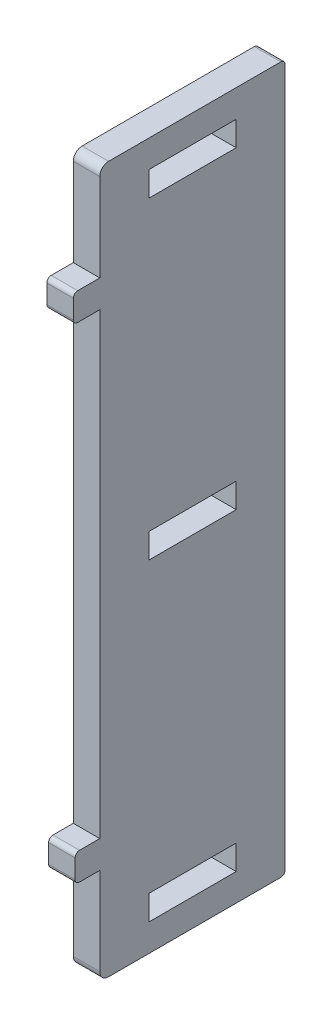
from build123d import *

# Parameters (mm, degrees)
SKETCH_1_W      = 9.9
SKETCH_1_H      = 2.8
SKETCH_1_W_2    = 3
SKETCH_1_H_2    = 3.12
EXTRUDE_1_DEPTH = 3
FILLET_1_R      = 1
FILLET_2_R      = 0.5


with BuildPart() as part:
    # Эскиз1 → Бобышка-Вытянуть1 (new body)
    with BuildSketch(Plane(origin=(0, 0, 0), x_dir=(0, 0, -1), z_dir=(1, 0, 0))):
        Polygon((-13.3, -25.94), (-13.3, -29.06), (-10.5, -29.06), (-10.5, -40), (10.5, -40), (10.5, 40), (-10.5, 40), (-10.5, -25.94), align=None)
        with Locations((0, 35.5)):
            Rectangle(SKETCH_1_W, SKETCH_1_H, mode=Mode.SUBTRACT)
        Rectangle(SKETCH_1_W, SKETCH_1_H, mode=Mode.SUBTRACT)
        with Locations((0, -35.5)):
            Rectangle(SKETCH_1_W, SKETCH_1_H, mode=Mode.SUBTRACT)
        with Locations((-12, 27.5)):
            Rectangle(SKETCH_1_W_2, SKETCH_1_H_2)
    extrude(amount=EXTRUDE_1_DEPTH)

    # Скругление1
    fillet_1_edges = [part.edges().sort_by_distance(p)[0] for p in [
        (1.5, 40, 10.5),
        (1.5, -40, 10.5),
    ]]
    fillet(fillet_1_edges, radius=FILLET_1_R)

    # Скругление2
    fillet_2_edges = [part.edges().sort_by_distance(p)[0] for p in [
        (1.5, -25.94, 13.3),
        (1.5, 25.94, 13.5),
        (1.5, 29.06, 13.5),
        (1.5, 40, -10.5),
        (1.5, -40, -10.5),
        (1.5, -29.06, 13.3),
    ]]
    fillet(fillet_2_edges, radius=FILLET_2_R)


solid = part.part
